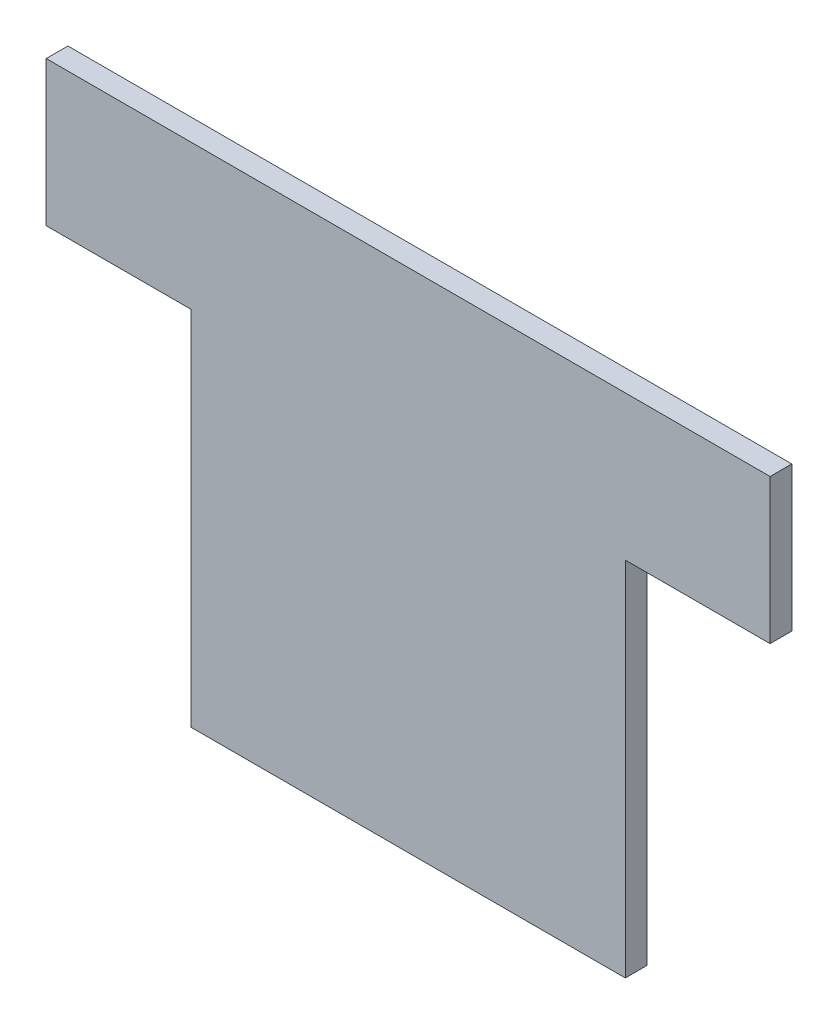
from build123d import *

# Parameters (mm, degrees)
BOSS_EXTRUDE1_DEPTH = 3


with BuildPart() as part:
    # Sketch1 → Boss-Extrude1 (new body)
    with BuildSketch(Plane.XY):
        Polygon((-30, -20), (-30, -70), (30, -70), (30, -20), (50, -20), (50, 0), (-50, 0), (-50, -20), align=None)
    extrude(amount=BOSS_EXTRUDE1_DEPTH)


solid = part.part
